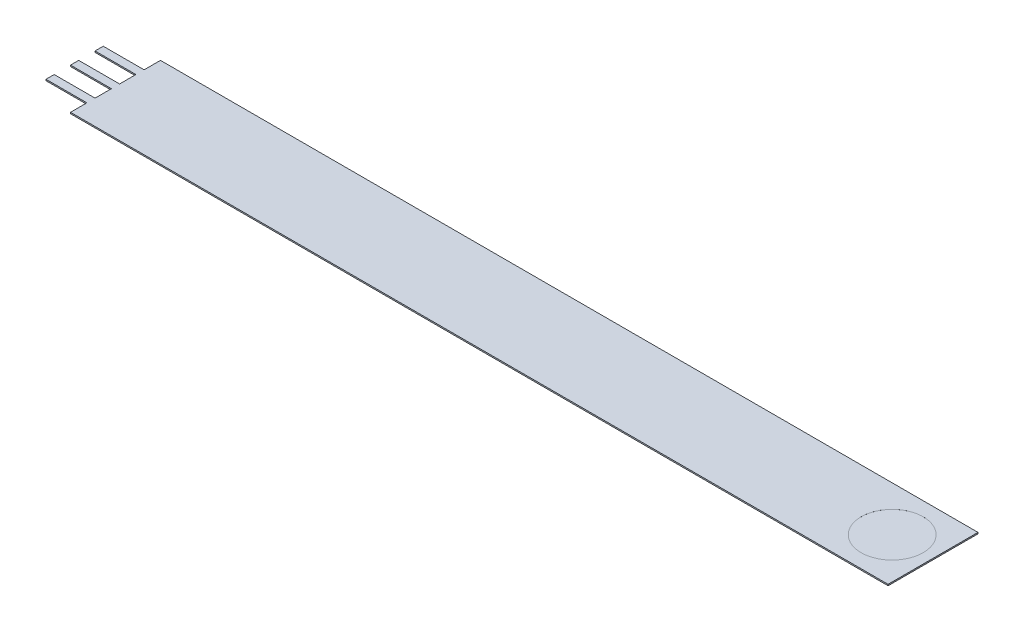
from build123d import *

# Parameters (mm, degrees)
BOSS_EXTRUDE1_DEPTH = 0.2032
SKETCH2_R           = 4.826
CUT_EXTRUDE1_DEPTH  = 0.00254


with BuildPart() as part:
    # Sketch1 → Boss-Extrude1 (new body)
    with BuildSketch(Plane(origin=(0, 0, 0), x_dir=(1, 0, 0), z_dir=(0, 1, 0))):
        Polygon((-120.65, -0.635), (-127, -0.635), (-127, 0.635), (-120.65, 0.635), (-120.65, 3.175), (-127, 3.175), (-127, 4.445), (-120.65, 4.445), (-120.65, 6.985), (6.35, 6.985), (6.35, -6.985), (-120.65, -6.985), (-120.65, -4.445), (-127, -4.445), (-127, -3.175), (-120.65, -3.175), align=None)
    extrude(amount=BOSS_EXTRUDE1_DEPTH)

    # Sketch2 → Cut-Extrude1 (cut)
    with BuildSketch(Plane(origin=(0, 0.2032, 0), x_dir=(1, 0, 0), z_dir=(0, 1, 0))):
        Circle(SKETCH2_R)
    extrude(amount=-CUT_EXTRUDE1_DEPTH, mode=Mode.SUBTRACT)


solid = part.part
